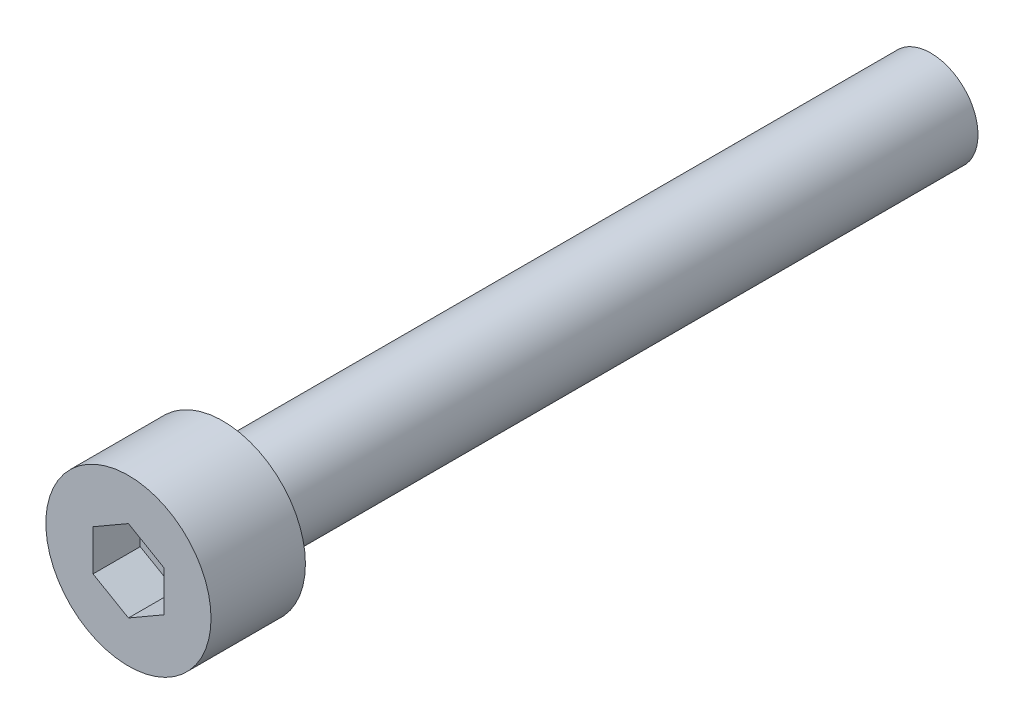
from build123d import *

# Parameters (mm, degrees)
SKETCH1_R           = 3.5
BOSS_EXTRUDE1_DEPTH = 4
CUT_EXTRUDE1_DEPTH  = 2
SKETCH3_R           = 2
BOSS_EXTRUDE2_DEPTH = 30


with BuildPart() as part:
    # Sketch1 → Boss-Extrude1 (new body)
    with BuildSketch(Plane.XY):
        Circle(SKETCH1_R)
    extrude(amount=BOSS_EXTRUDE1_DEPTH)

    # Sketch2 → Cut-Extrude1 (cut)
    with BuildSketch(Plane.XY.offset(4)):
        Polygon((0, -1.732050808), (1.5, -0.866025404), (1.5, 0.866025404), (0, 1.732050808), (-1.5, 0.866025404), (-1.5, -0.866025404), align=None)
    extrude(amount=-CUT_EXTRUDE1_DEPTH, mode=Mode.SUBTRACT)

    # Sketch3 → Boss-Extrude2 (add)
    with BuildSketch(Plane(origin=(0, 0, 0), x_dir=(-1, 0, 0), z_dir=(0, 0, -1))):
        Circle(SKETCH3_R)
    extrude(amount=BOSS_EXTRUDE2_DEPTH)


solid = part.part
